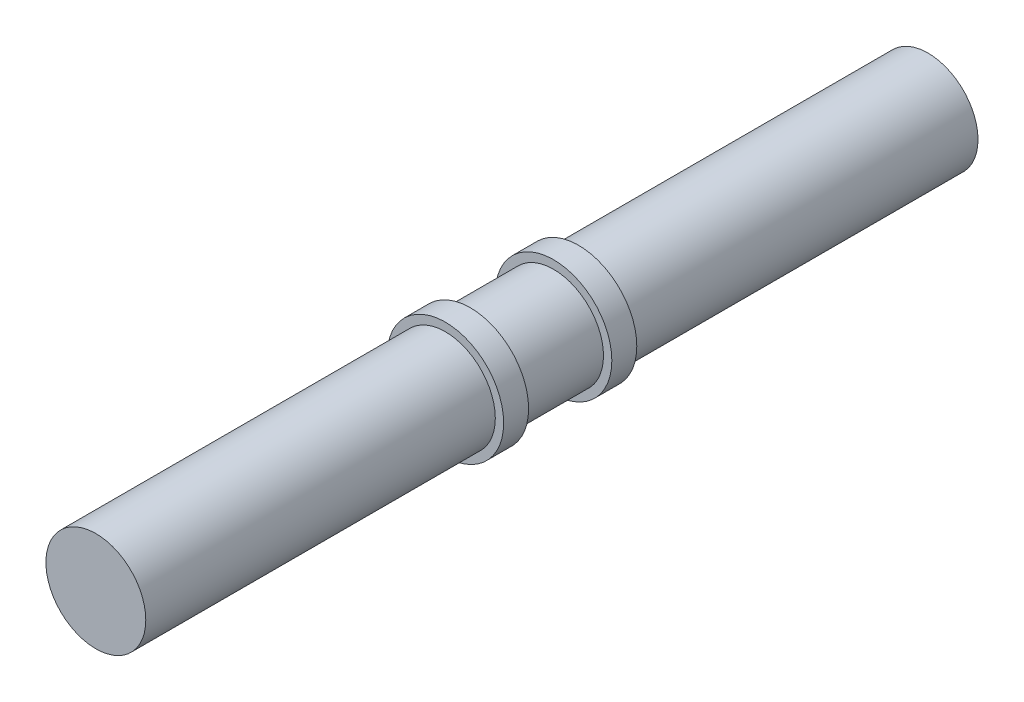
from build123d import *

# Parameters (mm, degrees)
SKETCH1_R           = 6
BOSS_EXTRUDE1_DEPTH = 42
SKETCH2_R           = 7
BOSS_EXTRUDE2_DEPTH = 3
SKETCH3_R           = 6
BOSS_EXTRUDE3_DEPTH = 10
SKETCH4_R           = 7
BOSS_EXTRUDE4_DEPTH = 3
SKETCH5_R           = 6
BOSS_EXTRUDE5_DEPTH = 42


with BuildPart() as part:
    # Sketch1 → Boss-Extrude1 (new body)
    with BuildSketch(Plane.XY):
        Circle(SKETCH1_R)
    extrude(amount=BOSS_EXTRUDE1_DEPTH)

    # Sketch2 → Boss-Extrude2 (add)
    with BuildSketch(Plane.XY.offset(42)):
        Circle(SKETCH2_R)
    extrude(amount=BOSS_EXTRUDE2_DEPTH)

    # Sketch3 → Boss-Extrude3 (add)
    with BuildSketch(Plane.XY.offset(45)):
        Circle(SKETCH3_R)
    extrude(amount=BOSS_EXTRUDE3_DEPTH)

    # Sketch4 → Boss-Extrude4 (add)
    with BuildSketch(Plane.XY.offset(55)):
        Circle(SKETCH4_R)
    extrude(amount=BOSS_EXTRUDE4_DEPTH)

    # Sketch5 → Boss-Extrude5 (add)
    with BuildSketch(Plane.XY.offset(58)):
        Circle(SKETCH5_R)
    extrude(amount=BOSS_EXTRUDE5_DEPTH)


solid = part.part
